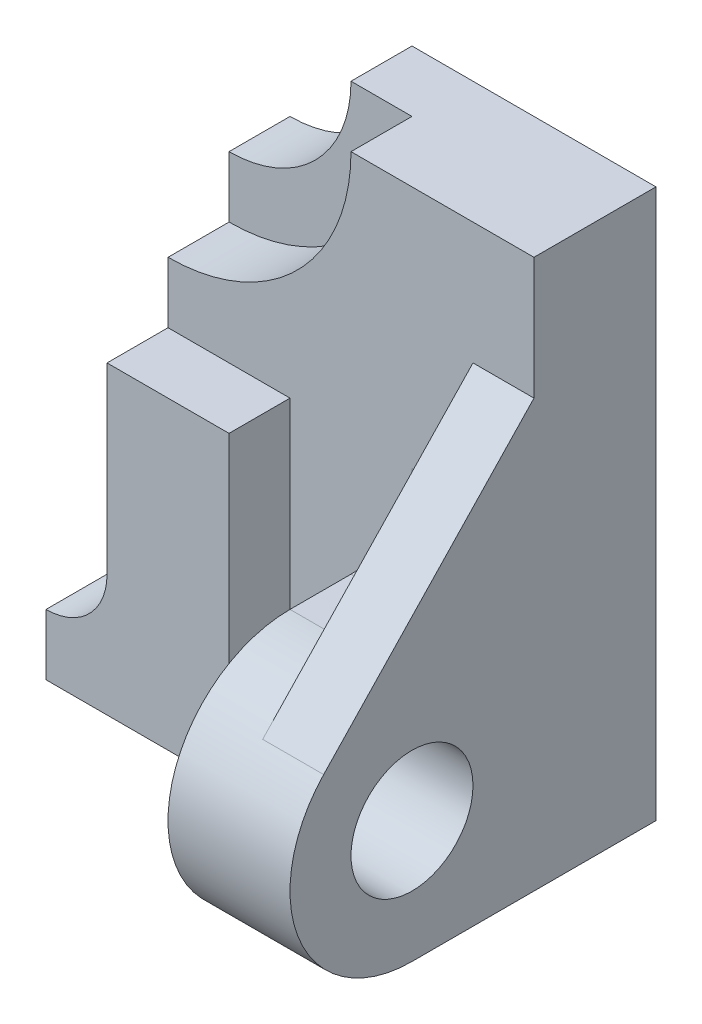
from build123d import *

# Parameters (mm, degrees)
SKETCH1_W           = 6
SKETCH1_H           = 9
BOSS_EXTRUDE1_DEPTH = 2
CUT_EXTRUDE1_DEPTH  = 3
CUT_EXTRUDE2_DEPTH  = 1
SKETCH4_W           = 2
SKETCH4_H           = 5
BOSS_EXTRUDE2_DEPTH = 1
BOSS_EXTRUDE3_DEPTH = 3
SKETCH7_R           = 1
BOSS_EXTRUDE4_DEPTH = 2
BOSS_EXTRUDE5_DEPTH = 1


with BuildPart() as part:
    # Sketch1 → Boss-Extrude1 (new body)
    with BuildSketch(Plane.XY):
        Rectangle(SKETCH1_W, SKETCH1_H)
    extrude(amount=BOSS_EXTRUDE1_DEPTH)

    # Sketch2 → Cut-Extrude1 (cut, through all)
    with BuildSketch(Plane.XY.offset(2)):
        with BuildLine():
            Line((-1, 4.5), (-3, 4.5))
            Line((-3, 4.5), (-3, 2.5))
            ThreePointArc((-3, 2.5), (-1.585786438, 3.085786438), (-1, 4.5))
        make_face()
    extrude(amount=-CUT_EXTRUDE1_DEPTH, mode=Mode.SUBTRACT)

    # Sketch3 → Cut-Extrude2 (cut)
    with BuildSketch(Plane.XY.offset(2)):
        with BuildLine():
            Line((0, 4.5), (-3, 4.5))
            Line((-3, 4.5), (-3, 1.5))
            ThreePointArc((-3, 1.5), (-0.878679656, 2.378679656), (0, 4.5))
        make_face()
    extrude(amount=-CUT_EXTRUDE2_DEPTH, mode=Mode.SUBTRACT)

    # Sketch4 → Boss-Extrude2 (add)
    with BuildSketch(Plane.XY.offset(2)):
        with Locations((-2, -2)):
            Rectangle(SKETCH4_W, SKETCH4_H)
    extrude(amount=BOSS_EXTRUDE2_DEPTH)

    # Sketch5 → Boss-Extrude3 (add)
    with BuildSketch(Plane.XY.offset(3)):
        with BuildLine():
            Line((-3, -4.5), (-4, -4.5))
            Line((-4, -4.5), (-4, -3.5))
            ThreePointArc((-4, -3.5), (-3.292893219, -3.207106781), (-3, -2.5))
            Line((-3, -2.5), (-3, -4.5))
        make_face()
    extrude(amount=-BOSS_EXTRUDE3_DEPTH)

    # Sketch7 → Boss-Extrude4 (add)
    with BuildSketch(Plane(origin=(3, 0, 0), x_dir=(0, 0, -1), z_dir=(1, 0, 0))):
        with BuildLine():
            Line((-4, -4.5), (-2, -4.5))
            Line((-2, -4.5), (-2, 0.5))
            ThreePointArc((-2, 0.5), (-2.292893219, -0.207106781), (-3, -0.5))
            Line((-3, -0.5), (-4, -0.5))
            ThreePointArc((-4, -0.5), (-6, -2.5), (-4, -4.5))
        make_face()
        with Locations((-4, -2.5)):
            Circle(SKETCH7_R, mode=Mode.SUBTRACT)
    extrude(amount=-BOSS_EXTRUDE4_DEPTH)

    # Sketch8 → Boss-Extrude5 (add)
    with BuildSketch(Plane(origin=(3, 0, 0), x_dir=(0, 0, -1), z_dir=(1, 0, 0))):
        with BuildLine():
            Line((-2, 2.5), (-5.448275862, -1.120689655))
            ThreePointArc((-5.448275862, -1.120689655), (-4.787838597, -0.66170994), (-4, -0.5))
            Line((-4, -0.5), (-3, -0.5))
            ThreePointArc((-3, -0.5), (-2.292893219, -0.207106781), (-2, 0.5))
            Line((-2, 0.5), (-2, 2.5))
        make_face()
    extrude(amount=-BOSS_EXTRUDE5_DEPTH)


solid = part.part
